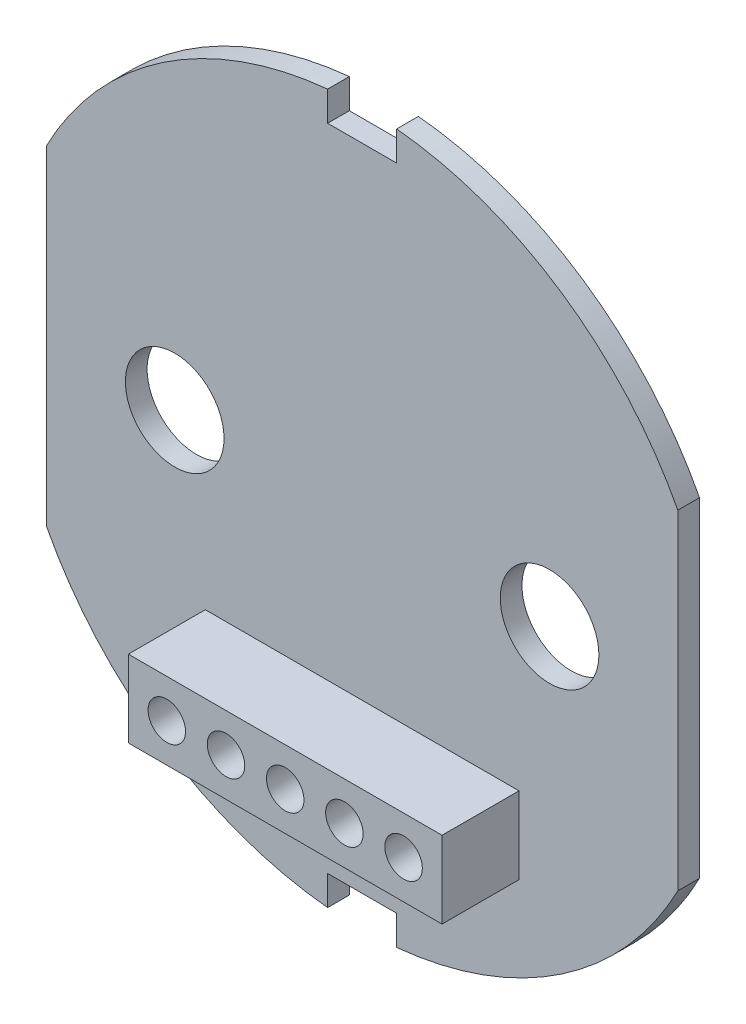
from build123d import *

# Parameters (mm, degrees)
IZIM1_R                     = 0.95
IZIM1_R_2                   = 2.5
Y_KSEKLIK_EKSTR_ZYON4_DEPTH = 1.1
IZIM2_W                     = 15.9
IZIM2_H                     = 3.9
IZIM2_R                     = 0.95
Y_KSEKLIK_EKSTR_ZYON5_DEPTH = 3.9


with BuildPart() as part:
    # Çizim1 → Yükseklik-Ekstrüzyon4 (new body)
    with BuildSketch(Plane.XY):
        with BuildLine():
            ThreePointArc((-16, -8.354789046), (-10.092299035, -14.964892254), (-1.75, -17.964965906))
            Line((-1.75, -17.964965906), (-1.75, -16.464965906))
            Line((-1.75, -16.464965906), (1.75, -16.464965906))
            Line((1.75, -16.464965906), (1.75, -17.964965906))
            ThreePointArc((1.75, -17.964965906), (10.092299035, -14.964892254), (16, -8.354789046))
            Line((16, -8.354789046), (16, 8.354789046))
            ThreePointArc((16, 8.354789046), (10.092299035, 14.964892254), (1.75, 17.964965906))
            Line((1.75, 17.964965906), (1.75, 16.464965906))
            Line((1.75, 16.464965906), (-1.75, 16.464965906))
            Line((-1.75, 16.464965906), (-1.75, 17.964965906))
            ThreePointArc((-1.75, 17.964965906), (-10.092299035, 14.964892254), (-16, 8.354789046))
            Line((-16, 8.354789046), (-16, -8.354789046))
        make_face()
        with Locations((-6, -9.939079606)):
            Circle(IZIM1_R, mode=Mode.SUBTRACT)
        with Locations((-3, -9.939079606)):
            Circle(IZIM1_R, mode=Mode.SUBTRACT)
        with Locations((0, -9.939079606)):
            Circle(IZIM1_R, mode=Mode.SUBTRACT)
        with Locations((3, -9.939079606)):
            Circle(IZIM1_R, mode=Mode.SUBTRACT)
        with Locations((6, -9.939079606)):
            Circle(IZIM1_R, mode=Mode.SUBTRACT)
        with Locations((-9.5, 0)):
            Circle(IZIM1_R_2, mode=Mode.SUBTRACT)
        with Locations((9.5, 0)):
            Circle(IZIM1_R_2, mode=Mode.SUBTRACT)
    extrude(amount=Y_KSEKLIK_EKSTR_ZYON4_DEPTH)

    # Çizim2 → Yükseklik-Ekstrüzyon5 (add)
    with BuildSketch(Plane.XY.offset(1.1)):
        with Locations((0, -9.939079606)):
            Rectangle(IZIM2_W, IZIM2_H)
        with Locations((-6, -9.939079606)):
            Circle(IZIM2_R, mode=Mode.SUBTRACT)
        with Locations((3, -9.939079606)):
            Circle(IZIM2_R, mode=Mode.SUBTRACT)
        with Locations((0, -9.939079606)):
            Circle(IZIM2_R, mode=Mode.SUBTRACT)
        with Locations((6, -9.939079606)):
            Circle(IZIM2_R, mode=Mode.SUBTRACT)
        with Locations((-3, -9.939079606)):
            Circle(IZIM2_R, mode=Mode.SUBTRACT)
    extrude(amount=Y_KSEKLIK_EKSTR_ZYON5_DEPTH)


solid = part.part
